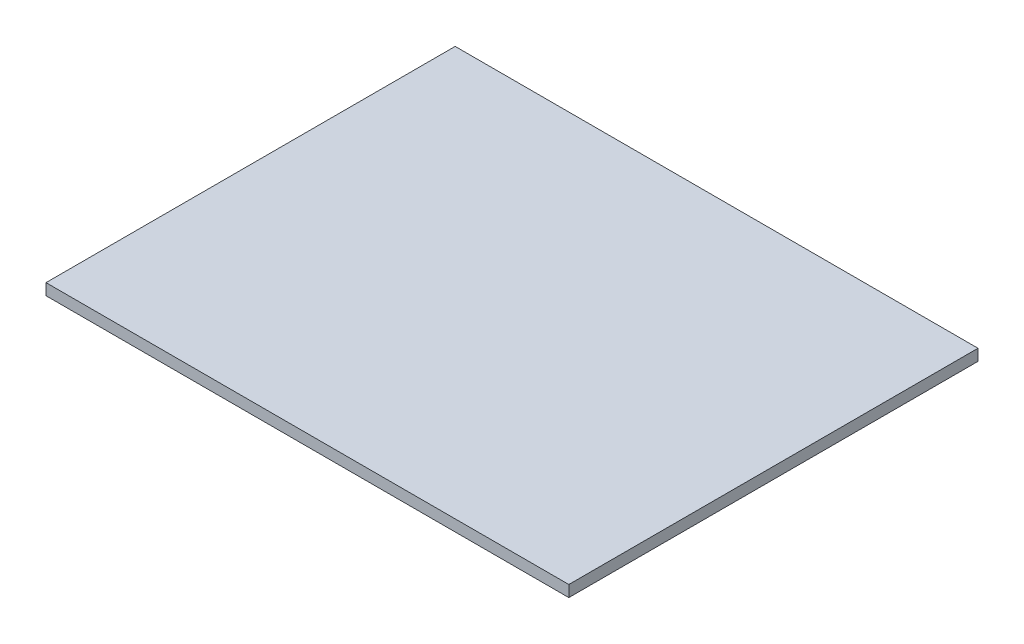
from build123d import *

# Parameters (mm, degrees)
ESQUISSE1_W        = 46
ESQUISSE1_H        = 36
BOSS_EXTRU_1_DEPTH = 1


with BuildPart() as part:
    # Esquisse1 → Boss.-Extru.1 (new body)
    with BuildSketch(Plane(origin=(0, 0, 0), x_dir=(1, 0, 0), z_dir=(0, 1, 0))):
        Rectangle(ESQUISSE1_W, ESQUISSE1_H)
    extrude(amount=BOSS_EXTRU_1_DEPTH)


solid = part.part
